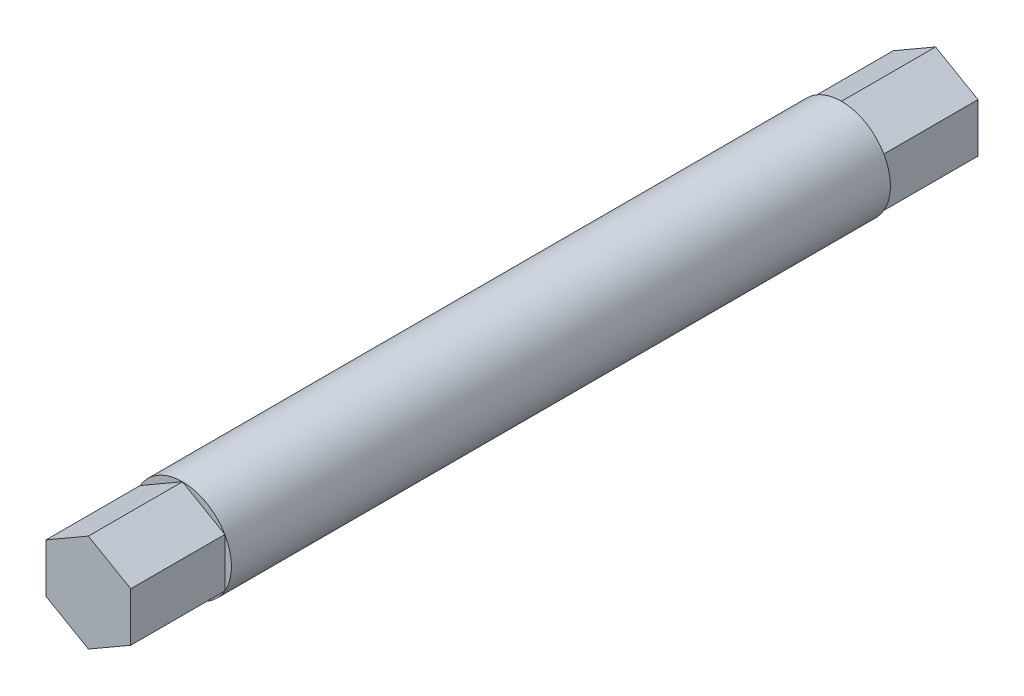
from build123d import *

# Parameters (mm, degrees)
SALIENTE_EXTRUIR1_DEPTH = 10
CROQUIS2_R              = 5.196152423
SALIENTE_EXTRUIR3_DEPTH = 70
SALIENTE_EXTRUIR4_DEPTH = 10


with BuildPart() as part:
    # Croquis1 → Saliente-Extruir1 (new body)
    with BuildSketch(Plane.XY):
        Polygon((0, 5.196152423), (-4.5, 2.598076211), (-4.5, -2.598076211), (0, -5.196152423), (4.5, -2.598076211), (4.5, 2.598076211), align=None)
    extrude(amount=SALIENTE_EXTRUIR1_DEPTH)

    # Croquis2 → Saliente-Extruir3 (add)
    with BuildSketch(Plane.XY.offset(10)):
        Circle(CROQUIS2_R)
    extrude(amount=SALIENTE_EXTRUIR3_DEPTH)

    # Croquis3 → Saliente-Extruir4 (add)
    with BuildSketch(Plane.XY.offset(80)):
        Polygon((0, 5.196152423), (-4.5, 2.598076211), (-4.5, -2.598076211), (0, -5.196152423), (4.5, -2.598076211), (4.5, 2.598076211), align=None)
    extrude(amount=SALIENTE_EXTRUIR4_DEPTH)


solid = part.part
